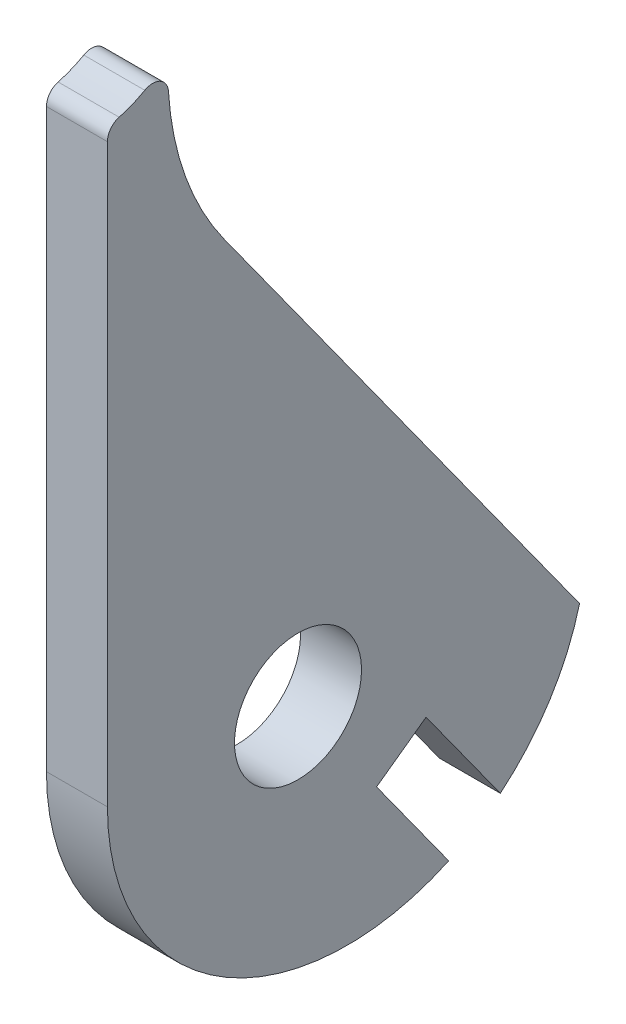
from build123d import *

# Parameters (mm, degrees)
BOSS_EXTRUDE1_DEPTH = 1.524
SKETCH2_R           = 3.175
CUT_EXTRUDE1_DEPTH  = 34.816187625
CUT_EXTRUDE2_DEPTH  = 34.816187625


with BuildPart() as part:
    # Sketch1 → Boss-Extrude1 (new, symmetric)
    with BuildSketch(Plane(origin=(0, 0, 0), x_dir=(0, 0, -1), z_dir=(1, 0, 0))):
        with BuildLine():
            Line((-9.525, 29.203153615), (-9.525, 0.413383537))
            ThreePointArc((-9.525, 0.413383537), (0.953114694, -11.479629163), (14.071488999, -2.58339995))
            Line((14.071488999, -2.58339995), (-3.690440969, 22.065775388))
            ThreePointArc((-3.690440969, 22.065775388), (-5.633424794, 25.762785311), (-6.474725684, 29.85366313))
            ThreePointArc((-6.474725684, 29.85366313), (-6.888835567, 30.502157859), (-7.658237218, 30.494842983))
            ThreePointArc((-7.658237218, 30.494842983), (-8.281558069, 30.191808808), (-8.938016281, 29.969499991))
            ThreePointArc((-8.938016281, 29.969499991), (-9.361392761, 29.685812049), (-9.525, 29.203153615))
        make_face()
    extrude(amount=BOSS_EXTRUDE1_DEPTH, both=True)

    # Sketch2 → Cut-Extrude1 (cut, through all)
    with BuildSketch(Plane(origin=(1.524, 0, 0), x_dir=(0, 0, -1), z_dir=(1, 0, 0))):
        Circle(SKETCH2_R)
    extrude(amount=-CUT_EXTRUDE1_DEPTH, mode=Mode.SUBTRACT)

    # Sketch3 → Cut-Extrude2 (cut, through all)
    with BuildSketch(Plane(origin=(1.524, 0, 0), x_dir=(0, 0, -1), z_dir=(1, 0, 0))):
        with BuildLine():
            Line((3.926398482, -5.448872099), (7.531186188, -10.451427812))
            ThreePointArc((7.531186188, -10.451427812), (8.873585882, -9.717582903), (10.111597952, -8.818755111))
            Line((10.111597952, -8.818755111), (6.399264057, -3.66695183))
            Line((6.399264057, -3.66695183), (3.926398482, -5.448872099))
        make_face()
    extrude(amount=-CUT_EXTRUDE2_DEPTH, mode=Mode.SUBTRACT)


solid = part.part
